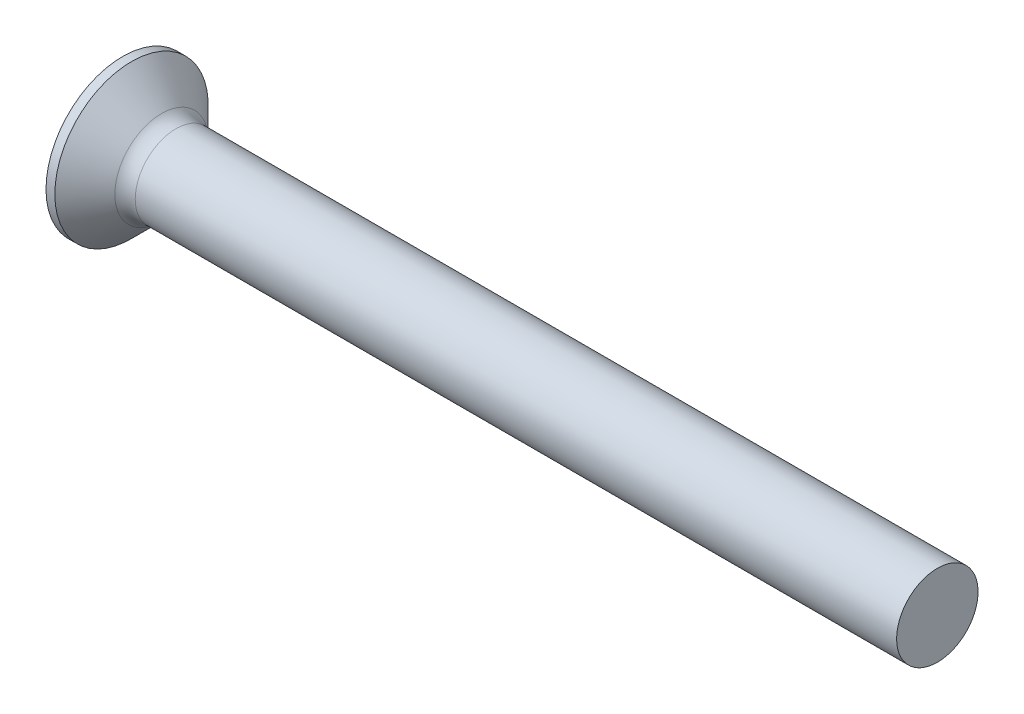
from build123d import *

# Parameters (mm, degrees)
FILLET1_R    = 1.5
SKETCH3_W    = 1.42
SKETCH3_H    = 7.1
SKETCH4_W    = 1.42
SKETCH4_H    = 3.26092226
RECPAT_COUNT = 2
RECPAT_ANGLE = 90


with BuildPart() as part:
    # BodySke → Base-Revolve (revolve)
    with BuildSketch(Plane.XY):
        with BuildLine():
            Line((0, 0), (61.4, 0))
            Line((61.4, 0), (61.4, 3))
            Line((61.4, 3), (4.7, 3))
            Line((4.7, 3), (2.05, 5.65))
            Line((2.05, 5.65), (1.4, 5.65))
            ThreePointArc((1.4, 5.65), (0.355213526, 2.910433816), (0, 0))
        make_face()
    revolve(axis=Axis((-15.875, 0, 0), (1, 0, 0)))

    # Fillet1
    fillet1_edges = [part.edges().sort_by_distance(p)[0] for p in [
        (4.7, -3, 0),
    ]]
    fillet(fillet1_edges, radius=FILLET1_R)

    # Sketch3 → Recess section 0
    with BuildSketch(Plane(origin=(0, 0, 0), x_dir=(0, 0, -1), z_dir=(1, 0, 0))):
        Rectangle(SKETCH3_W, SKETCH3_H)
    # Sketch4 → Recess section 1
    with BuildSketch(Plane(origin=(3.85, 0, 0), x_dir=(0, 0, -1), z_dir=(1, 0, 0))):
        Rectangle(SKETCH4_W, SKETCH4_H)
    recess = loft(mode=Mode.SUBTRACT)

    # RecPat: Recess ×2 about axis
    recpat_axis = Axis((0, 0, 0), (1, 0, 0))
    for i in range(1, RECPAT_COUNT):
        add(recess.rotate(recpat_axis, i * RECPAT_ANGLE / (RECPAT_COUNT - 1)), mode=Mode.SUBTRACT)

    # RecCorSke → RecessCore (revolve, cut)
    with BuildSketch(Plane.XY):
        Polygon((0, 0), (0, 1.549718226), (3.85, 1.2805), (4.266059671, 0), align=None)
    revolve(axis=Axis((-3.175, 0, 0), (1, 0, 0)), mode=Mode.SUBTRACT)


solid = part.part
